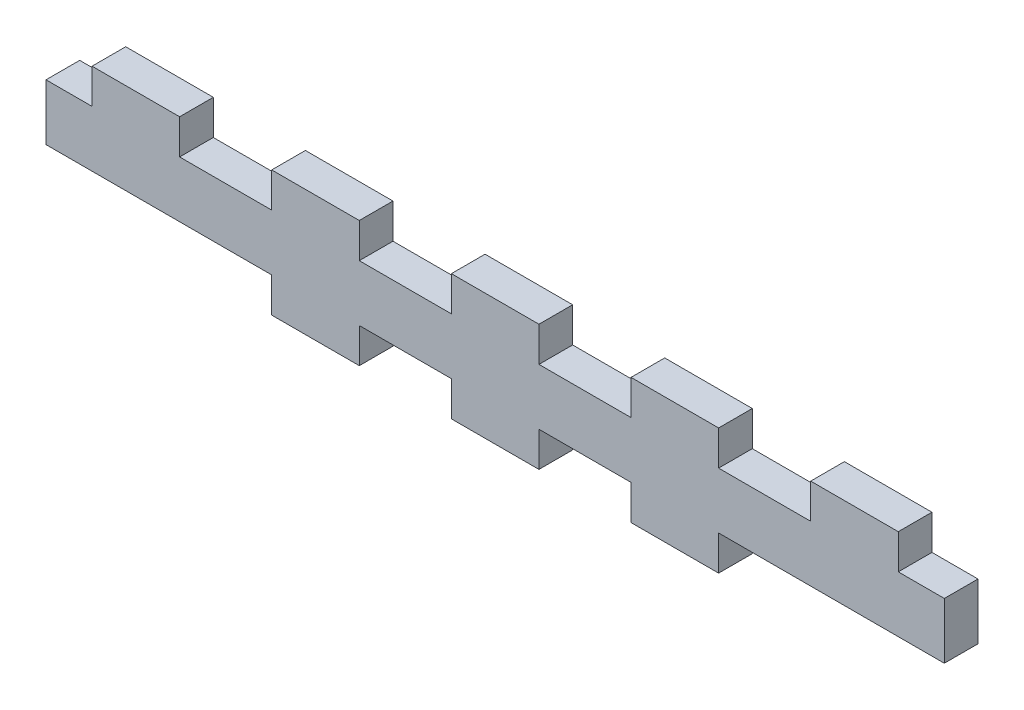
from build123d import *

# Parameters (mm, degrees)
SKETCH1_W           = 80
SKETCH1_H           = 11.2
BOSS_EXTRUDE1_DEPTH = 3
SKETCH3_W           = 20.2
SKETCH3_H           = 3.2
SKETCH3_W_2         = 4.2
SKETCH3_W_3         = 8.2
CUT_EXTRUDE1_DEPTH  = 4


with BuildPart() as part:
    # Sketch1 → Boss-Extrude1 (new body)
    with BuildSketch(Plane.XY):
        with Locations((40, -5.6)):
            Rectangle(SKETCH1_W, SKETCH1_H)
    extrude(amount=BOSS_EXTRUDE1_DEPTH)

    # Sketch3 → Cut-Extrude1 (cut, through all)
    with BuildSketch(Plane.XY):
        with Locations((10, -9.7)):
            Rectangle(SKETCH3_W, SKETCH3_H)
        with Locations((2, -1.5)):
            Rectangle(SKETCH3_W_2, SKETCH3_H)
        with Locations((32, -1.5)):
            Rectangle(SKETCH3_W_3, SKETCH3_H)
        with Locations((16, -1.5)):
            Rectangle(SKETCH3_W_3, SKETCH3_H)
        with Locations((48, -9.7)):
            Rectangle(SKETCH3_W_3, SKETCH3_H)
        with Locations((32, -9.7)):
            Rectangle(SKETCH3_W_3, SKETCH3_H)
        with Locations((70, -9.7)):
            Rectangle(SKETCH3_W, SKETCH3_H)
        with Locations((64, -1.5)):
            Rectangle(SKETCH3_W_3, SKETCH3_H)
        with Locations((48, -1.5)):
            Rectangle(SKETCH3_W_3, SKETCH3_H)
        with Locations((78, -1.5)):
            Rectangle(SKETCH3_W_2, SKETCH3_H)
    extrude(amount=CUT_EXTRUDE1_DEPTH, mode=Mode.SUBTRACT)


solid = part.part
